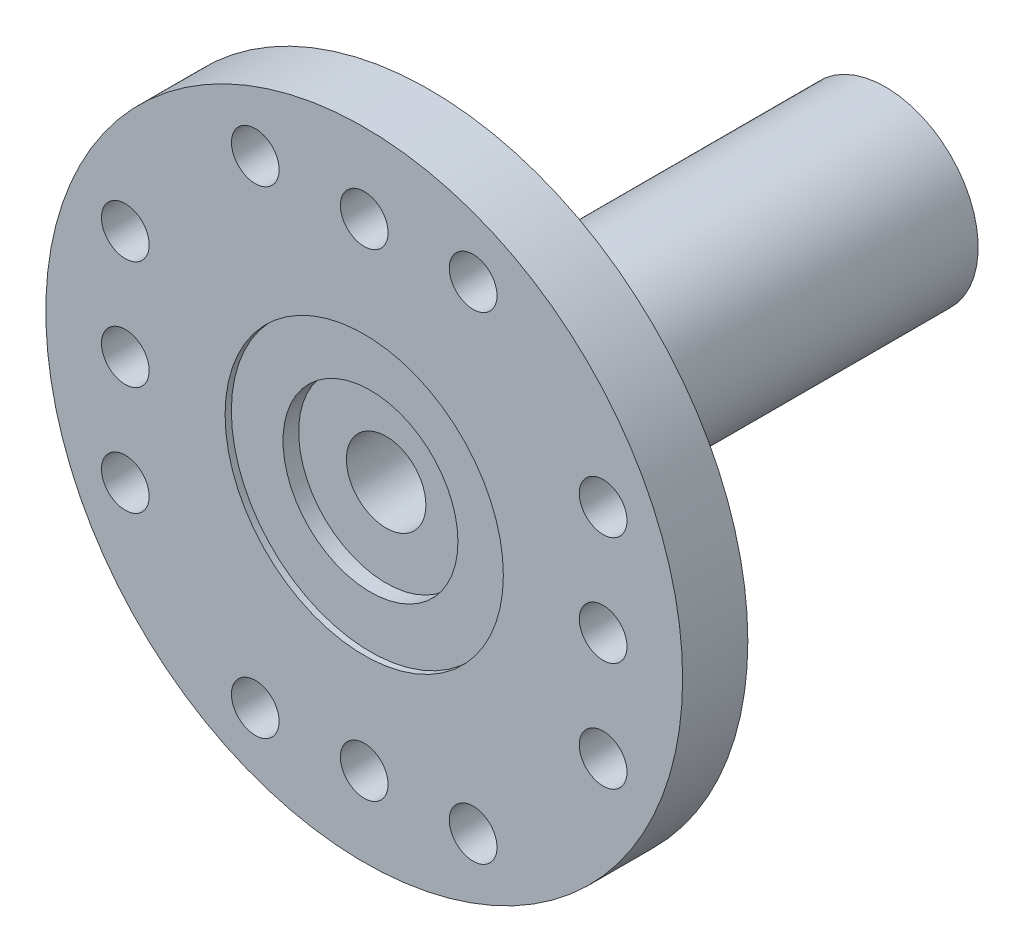
from build123d import *

# Parameters (mm, degrees)
SKETCH1_R          = 10.1727
EXTRUDE1_DEPTH     = 2.0828
SKETCH2_R          = 4.699
EXTRUDE2_DEPTH     = 3.302
SKETCH3_R          = 2.9591
EXTRUDE3_DEPTH     = 11.27
SKETCH4_R          = 4.445
CUT_EXTRUDE1_DEPTH = 0.2
SKETCH6_R          = 2.794
CUT_EXTRUDE2_DEPTH = 0.5
SKETCH7_R          = 1.27
CUT_EXTRUDE3_DEPTH = 22.483093204
CUT_EXTRUDE4_REACH = 24.008
SKETCH8_R          = 0.762
CIRPATTERN1_COUNT  = 4


with BuildPart() as part:
    # Sketch1 → Extrude1 (new body)
    with BuildSketch(Plane.XY):
        Circle(SKETCH1_R)
    extrude(amount=EXTRUDE1_DEPTH)

    # Sketch2 → Extrude2 (add)
    with BuildSketch(Plane(origin=(0, 0, 0), x_dir=(-1, 0, 0), z_dir=(0, 0, -1))):
        Circle(SKETCH2_R)
    extrude(amount=EXTRUDE2_DEPTH)

    # Sketch3 → Extrude3 (add)
    with BuildSketch(Plane(origin=(0, 0, -3.302), x_dir=(-1, 0, 0), z_dir=(0, 0, -1))):
        Circle(SKETCH3_R)
    extrude(amount=EXTRUDE3_DEPTH)

    # Sketch4 → Cut-Extrude1 (cut)
    with BuildSketch(Plane.XY.offset(2.0828)):
        Circle(SKETCH4_R)
    extrude(amount=-CUT_EXTRUDE1_DEPTH, mode=Mode.SUBTRACT)

    # Sketch6 → Cut-Extrude2 (cut)
    with BuildSketch(Plane.XY.offset(1.8828)):
        Circle(SKETCH6_R)
    extrude(amount=-CUT_EXTRUDE2_DEPTH, mode=Mode.SUBTRACT)

    # Sketch7 → Cut-Extrude3 (cut, through all)
    with BuildSketch(Plane.XY.offset(1.3828)):
        Circle(SKETCH7_R)
    extrude(amount=-CUT_EXTRUDE3_DEPTH, mode=Mode.SUBTRACT)

    # Sketch8 → Cut-Extrude4 (cut, up to next)
    with BuildSketch(Plane.XY.offset(2.0828), mode=Mode.PRIVATE) as cut_extrude4_sk1:
        with Locations((7.6327, 0)):
            Circle(SKETCH8_R)
    cut_extrude4_tool1 = extrude(cut_extrude4_sk1.sketch, amount=-CUT_EXTRUDE4_REACH, mode=Mode.PRIVATE) & part.part
    # Sketch8 → Cut-Extrude4 (cut, up to next)
    with BuildSketch(Plane.XY.offset(2.0828), mode=Mode.PRIVATE) as cut_extrude4_sk2:
        with Locations((7.6327, -3.4798)):
            Circle(SKETCH8_R)
    cut_extrude4_tool2 = extrude(cut_extrude4_sk2.sketch, amount=-CUT_EXTRUDE4_REACH, mode=Mode.PRIVATE) & part.part
    # Sketch8 → Cut-Extrude4 (cut, up to next)
    with BuildSketch(Plane.XY.offset(2.0828), mode=Mode.PRIVATE) as cut_extrude4_sk3:
        with Locations((7.6327, 3.4798)):
            Circle(SKETCH8_R)
    cut_extrude4_tool3 = extrude(cut_extrude4_sk3.sketch, amount=-CUT_EXTRUDE4_REACH, mode=Mode.PRIVATE) & part.part
    cut_extrude4_1 = cut_extrude4_tool1.solids().sort_by_distance((7.6327, 0, 2.0828))[0]
    add(cut_extrude4_1, mode=Mode.SUBTRACT)
    cut_extrude4_2 = cut_extrude4_tool2.solids().sort_by_distance((7.6327, -3.4798, 2.0828))[0]
    add(cut_extrude4_2, mode=Mode.SUBTRACT)
    cut_extrude4_3 = cut_extrude4_tool3.solids().sort_by_distance((7.6327, 3.4798, 2.0828))[0]
    add(cut_extrude4_3, mode=Mode.SUBTRACT)
    cut_extrude4 = cut_extrude4_1 + cut_extrude4_2 + cut_extrude4_3  # Cut-Extrude4 as one shape, for the pattern or mirror that repeats it

    # CirPattern1: Cut-Extrude4 ×4 about axis
    cirpattern1_axis = Axis((0, 0, 9.495004402), (0, 0, -1))
    for i in range(1, CIRPATTERN1_COUNT):
        add(cut_extrude4.rotate(cirpattern1_axis, i * 360 / CIRPATTERN1_COUNT), mode=Mode.SUBTRACT)


solid = part.part
